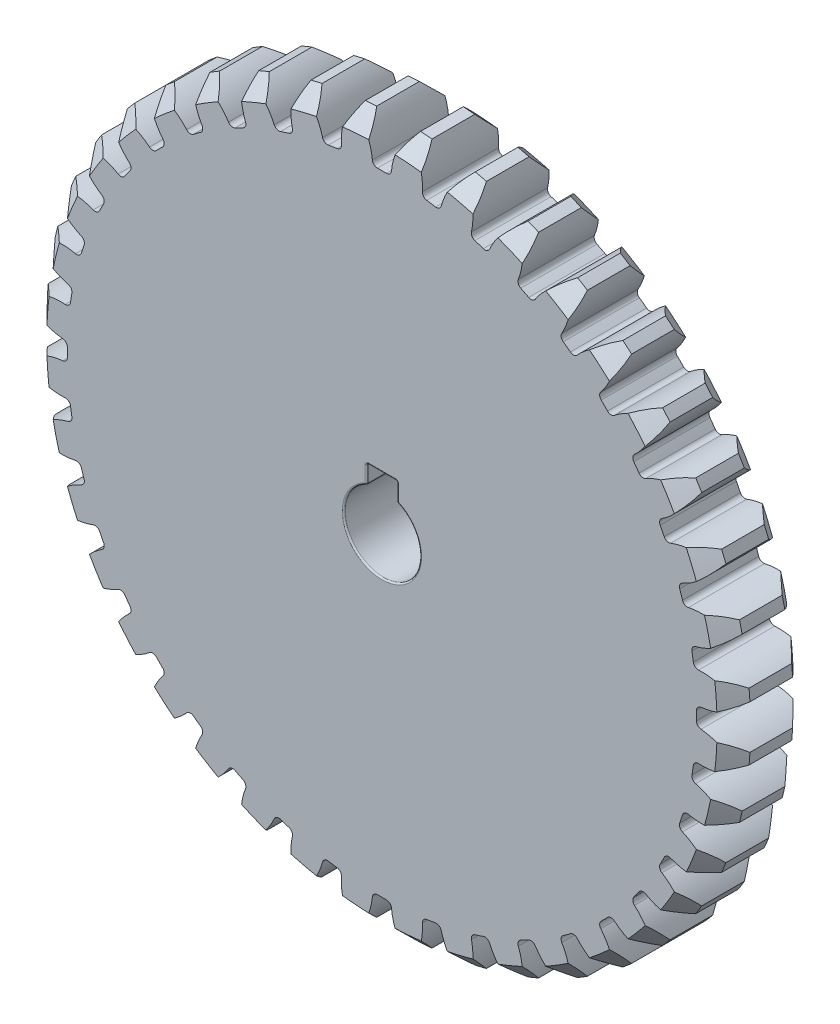
from build123d import *

# Parameters (mm, degrees)
SKETCH1_R                = 46.2
BOSS_EXTRUDE1_DEPTH      = 5
CUT_EXTRUDE1_DEPTH       = 6
FILLET1_R                = 0.66
CHAMFER1_SIZE            = 2.2
CIRPATTERN1_COUNT        = 40
FILLET1_OF_CIRPATTERN1_R = 0.66
CUT_EXTRUDE2_DEPTH       = 11.0000001
FILLET2_R                = 0.2


with BuildPart() as part:
    # Sketch1 → Boss-Extrude1 (new body, symmetric)
    with BuildSketch(Plane.XY):
        Circle(SKETCH1_R)
    extrude(amount=BOSS_EXTRUDE1_DEPTH, both=True)

    # Sketch2 → Cut-Extrude1 (cut, symmetric)
    with BuildSketch(Plane.XY):
        with BuildLine():
            ThreePointArc((2.874508928, 46.110489028), (1.67667641, 43.822688054), (1.213419035, 41.282170658))
            ThreePointArc((1.213419035, 41.282170658), (0, 41.3), (-1.213419035, 41.282170658))
            ThreePointArc((-1.213419035, 41.282170658), (-1.67667641, 43.822688054), (-2.874508928, 46.110489028))
            ThreePointArc((-2.874508928, 46.110489028), (0, 46.2), (2.874508928, 46.110489028))
        make_face()
    cut_extrude1 = extrude(amount=CUT_EXTRUDE1_DEPTH, both=True, mode=Mode.SUBTRACT)

    # Fillet1
    fillet1_edges = [part.edges().sort_by_distance(p)[0] for p in [
        (1.213419035, 41.282170658, 0),
        (-1.213419035, 41.282170658, 0),
    ]]
    fillet(fillet1_edges, radius=FILLET1_R)

    # Chamfer1
    chamfer1_edges = [part.edges().sort_by_distance(p)[0] for p in [
        (-31.635721009, -33.669290997, -5),
        (-31.635721009, -33.669290997, 5),
    ]]
    chamfer(chamfer1_edges, length=CHAMFER1_SIZE)

    # CirPattern1: Cut-Extrude1 ×40 about axis
    cirpattern1_axis = Axis((0, 0, 0), (0, 0, 1))
    for i in range(1, CIRPATTERN1_COUNT):
        add(cut_extrude1.rotate(cirpattern1_axis, i * 360 / CIRPATTERN1_COUNT), mode=Mode.SUBTRACT)

    # Fillet1 of CirPattern1
    fillet1_of_cirpattern1_edges = [part.edges().sort_by_distance(p)[0] for p in [
        (-5.25947445, 40.963739191, 0),
        (-7.656434116, 40.584098076, 0),
        (-11.602862218, 39.636644514, 0),
        (-13.910922378, 38.886710308, 0),
        (-17.660549011, 37.333564103, 0),
        (-19.822877564, 36.231802675, 0),
        (-23.283374475, 34.111207441, 0),
        (-25.246727716, 32.684747814, 0),
        (-28.332885987, 30.048919642, 0),
        (-30.048919642, 28.332885987, 0),
        (-32.684747814, 25.246727716, 0),
        (-34.111207441, 23.283374475, 0),
        (-36.231802675, 19.822877564, 0),
        (-37.333564103, 17.660549011, 0),
        (-38.886710308, 13.910922378, 0),
        (-39.636644514, 11.602862218, 0),
        (-40.584098076, 7.656434116, 0),
        (-40.963739191, 5.25947445, 0),
        (-41.282170658, 1.213419035, 0),
        (-41.282170658, -1.213419035, 0),
        (-40.963739191, -5.25947445, 0),
        (-40.584098076, -7.656434116, 0),
        (-39.636644514, -11.602862218, 0),
        (-38.886710308, -13.910922378, 0),
        (-37.333564103, -17.660549011, 0),
        (-36.231802675, -19.822877564, 0),
        (-34.111207441, -23.283374475, 0),
        (-32.684747814, -25.246727716, 0),
        (-30.048919642, -28.332885987, 0),
        (-28.332885987, -30.048919642, 0),
        (-25.246727716, -32.684747814, 0),
        (-23.283374475, -34.111207441, 0),
        (-19.822877564, -36.231802675, 0),
        (-17.660549011, -37.333564103, 0),
        (-13.910922378, -38.886710308, 0),
        (-11.602862218, -39.636644514, 0),
        (-7.656434116, -40.584098076, 0),
        (-5.25947445, -40.963739191, 0),
        (-1.213419035, -41.282170658, 0),
        (1.213419035, -41.282170658, 0),
        (5.25947445, -40.963739191, 0),
        (7.656434116, -40.584098076, 0),
        (11.602862218, -39.636644514, 0),
        (13.910922378, -38.886710308, 0),
        (17.660549011, -37.333564103, 0),
        (19.822877564, -36.231802675, 0),
        (23.283374475, -34.111207441, 0),
        (25.246727716, -32.684747814, 0),
        (28.332885987, -30.048919642, 0),
        (30.048919642, -28.332885987, 0),
        (32.684747814, -25.246727716, 0),
        (34.111207441, -23.283374475, 0),
        (36.231802675, -19.822877564, 0),
        (37.333564103, -17.660549011, 0),
        (38.886710308, -13.910922378, 0),
        (39.636644514, -11.602862218, 0),
        (40.584098076, -7.656434116, 0),
        (40.963739191, -5.25947445, 0),
        (41.282170658, -1.213419035, 0),
        (41.282170658, 1.213419035, 0),
        (40.963739191, 5.25947445, 0),
        (40.584098076, 7.656434116, 0),
        (39.636644514, 11.602862218, 0),
        (38.886710308, 13.910922378, 0),
        (37.333564103, 17.660549011, 0),
        (36.231802675, 19.822877564, 0),
        (34.111207441, 23.283374475, 0),
        (32.684747814, 25.246727716, 0),
        (30.048919642, 28.332885987, 0),
        (28.332885987, 30.048919642, 0),
        (25.246727716, 32.684747814, 0),
        (23.283374475, 34.111207441, 0),
        (19.822877564, 36.231802675, 0),
        (17.660549011, 37.333564103, 0),
        (13.910922378, 38.886710308, 0),
        (11.602862218, 39.636644514, 0),
        (7.656434116, 40.584098076, 0),
        (5.25947445, 40.963739191, 0),
    ]]
    fillet(fillet1_of_cirpattern1_edges, radius=FILLET1_OF_CIRPATTERN1_R)

    # Sketch3 → Cut-Extrude2 (cut, through all)
    with BuildSketch(Plane.XY.offset(5)):
        with BuildLine():
            Line((-2, 4.582575695), (-2, 7))
            Line((-2, 7), (2, 7))
            Line((2, 7), (2, 4.582575695))
            ThreePointArc((2, 4.582575695), (0, -5), (-2, 4.582575695))
        make_face()
    extrude(amount=-CUT_EXTRUDE2_DEPTH, mode=Mode.SUBTRACT)

    # Fillet2
    fillet2_edges = [part.edges().sort_by_distance(p)[0] for p in [
        (0, -5, -5),
        (2, 4.582575695, 0),
        (-2, 5.791287847, -5),
        (-2, 4.582575695, 0),
        (0, 7, -5),
        (-2, 7, 0),
        (2, 5.791287847, -5),
        (2, 7, 0),
        (0, -5, 5),
        (2, 5.791287847, 5),
        (0, 7, 5),
        (-2, 5.791287847, 5),
    ]]
    fillet(fillet2_edges, radius=FILLET2_R)


solid = part.part
